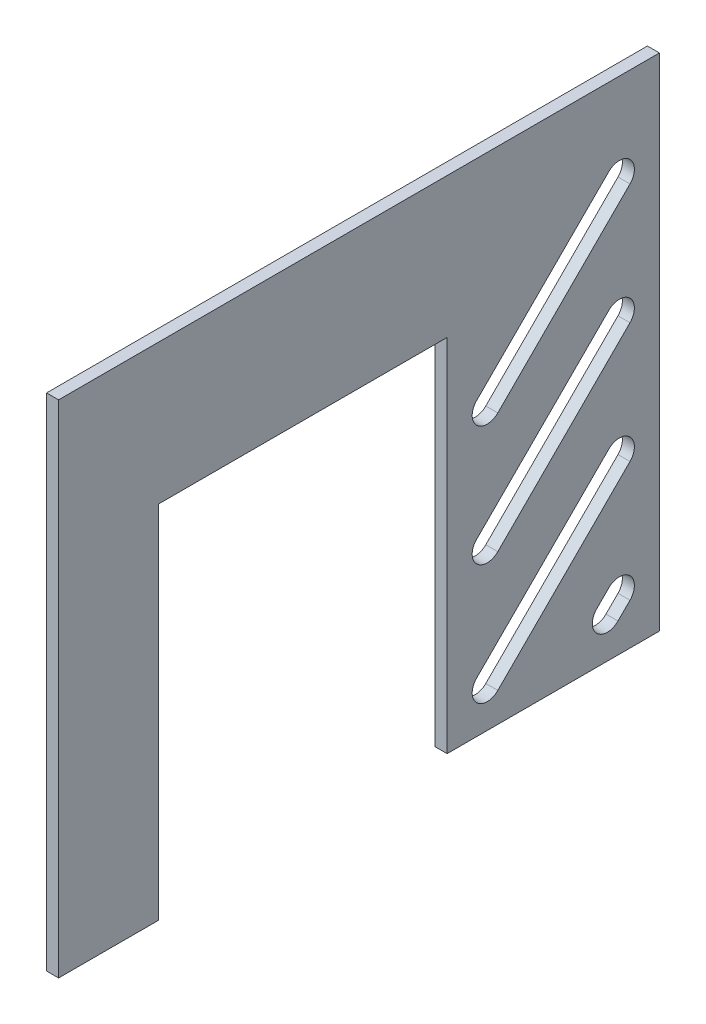
from build123d import *

# Parameters (mm, degrees)
BOSS_EXTRUDE1_DEPTH = 6
SKETCH2_W           = 106
SKETCH2_H           = 107.951063415
BOSS_EXTRUDE3_DEPTH = 6
CUT_EXTRUDE1_DEPTH  = 10
LPATTERN1_COUNT     = 3
LPATTERN1_PITCH     = 60


with BuildPart() as part:
    # Sketch1 → Boss-Extrude1 (new body)
    with BuildSketch(Plane(origin=(0, 0, 0), x_dir=(0, 0, -1), z_dir=(1, 0, 0))):
        Polygon((0, 0), (50, 0), (50, 180), (194, 180), (194, 0), (300, 0), (300, 250), (0, 250), align=None)
        with BuildLine():
            Line((274.696699141, 14.696699141), (208.696699141, 80.696699141))
            ThreePointArc((208.696699141, 80.696699141), (208.696699141, 91.303300859), (219.303300859, 91.303300859))
            Line((219.303300859, 91.303300859), (285.303300859, 25.303300859))
            ThreePointArc((285.303300859, 25.303300859), (285.303300859, 14.696699141), (274.696699141, 14.696699141))
        make_face(mode=Mode.SUBTRACT)
    extrude(amount=BOSS_EXTRUDE1_DEPTH)

    # Sketch2 → Boss-Extrude3 (add)
    with BuildSketch(Plane.ZY):
        with Locations((-247, 53.975531708)):
            Rectangle(SKETCH2_W, SKETCH2_H)
    extrude(amount=-BOSS_EXTRUDE3_DEPTH)

    # Sketch3 → Cut-Extrude1 (cut)
    with BuildSketch(Plane.ZY):
        with BuildLine():
            Line((-219.303300859, 14.696699141), (-285.303300859, 80.696699141))
            ThreePointArc((-285.303300859, 80.696699141), (-285.303300859, 91.303300859), (-274.696699141, 91.303300859))
            Line((-274.696699141, 91.303300859), (-208.696699141, 25.303300859))
            ThreePointArc((-208.696699141, 25.303300859), (-208.696699141, 14.696699141), (-219.303300859, 14.696699141))
        make_face()
        with BuildLine():
            Line((-279.303300859, 14.696699141), (-285.303300859, 20.696699141))
            ThreePointArc((-285.303300859, 20.696699141), (-285.303300859, 31.303300859), (-274.696699141, 31.303300859))
            Line((-274.696699141, 31.303300859), (-268.696699141, 25.303300859))
            ThreePointArc((-268.696699141, 25.303300859), (-268.696699141, 14.696699141), (-279.303300859, 14.696699141))
        make_face()
        with BuildLine():
            Line((-214.696699141, 273.303300859), (-208.696699141, 267.303300859))
            ThreePointArc((-208.696699141, 267.303300859), (-208.696699141, 256.696699141), (-219.303300859, 256.696699141))
            Line((-219.303300859, 256.696699141), (-225.303300859, 262.696699141))
            ThreePointArc((-225.303300859, 262.696699141), (-225.303300859, 273.303300859), (-214.696699141, 273.303300859))
        make_face()
    cut_extrude1 = extrude(amount=-CUT_EXTRUDE1_DEPTH, mode=Mode.SUBTRACT)

    # LPattern1: Cut-Extrude1 ×3
    with Locations(*[(0, i * LPATTERN1_PITCH, 0) for i in range(1, LPATTERN1_COUNT)]):
        add(cut_extrude1, mode=Mode.SUBTRACT)


solid = part.part
